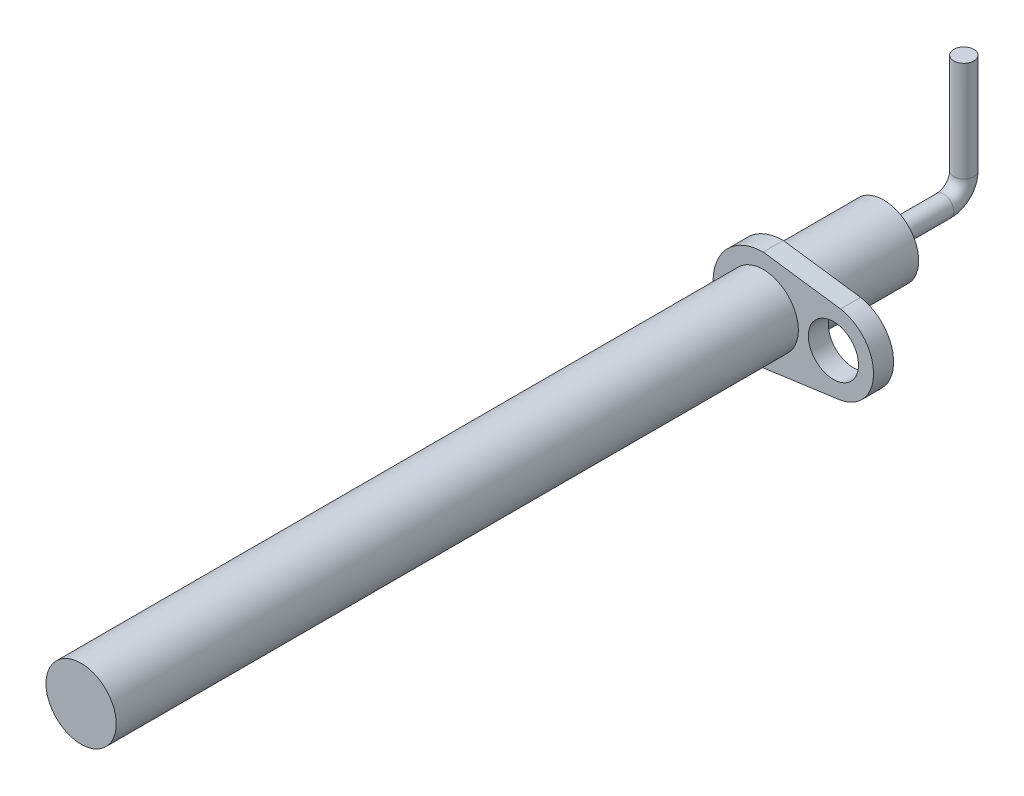
from build123d import *

# Parameters (mm, degrees)
SKETCH1_R           = 1.75
BOSS_EXTRUDE1_DEPTH = 40
SKETCH16_R          = 1.25
BOSS_EXTRUDE2_DEPTH = 1
SWEEP1_PROFILE_R    = 0.5


with BuildPart() as part:
    # Sketch1 → Boss-Extrude1 (new body)
    with BuildSketch(Plane.XY):
        Circle(SKETCH1_R)
    extrude(amount=BOSS_EXTRUDE1_DEPTH)

    # Sketch16 → Boss-Extrude2 (add)
    with BuildSketch(Plane(origin=(0, 0, 6), x_dir=(-1, 0, 0), z_dir=(0, 0, -1))):
        with BuildLine():
            Line((-3.851561771, 1.968858634), (0, 2.5))
            ThreePointArc((0, 2.5), (2.5, 0), (0, -2.5))
            Line((0, -2.5), (-3.851561771, -1.968858634))
            ThreePointArc((-3.851561771, -1.968858634), (-5.5, 0), (-3.851561771, 1.968858634))
        make_face()
        with Locations((-3.5, 0)):
            Circle(SKETCH16_R, mode=Mode.SUBTRACT)
    extrude(amount=BOSS_EXTRUDE2_DEPTH)

    # Sweep1: sweep along a curve in space
    with BuildLine() as sweep1_path:
        Line((0, 0, 0), (0, 0, -3))
        ThreePointArc((0, 0, -3), (0, 0.292893219, -3.707106781), (0, 1, -4))
        Line((0, 1, -4), (0, 6, -4))
    # Sweep1 profile (on start of the path) → Sweep1 (sweep)
    with BuildSketch(Plane(origin=(0, 0, 0), x_dir=(-1, 0, 0), z_dir=(0, 0, -1))):
        Circle(SWEEP1_PROFILE_R)
    sweep(path=sweep1_path.line)


solid = part.part
